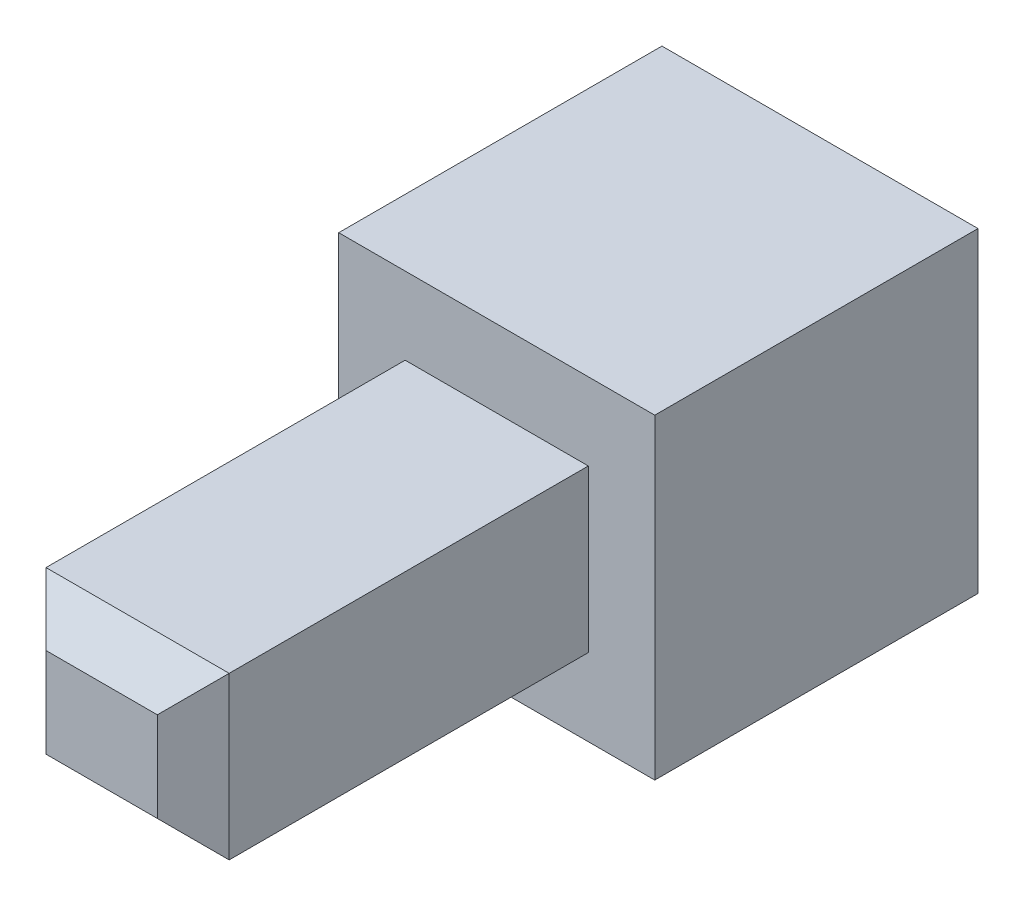
from build123d import *

# Parameters (mm, degrees)
BOSS_EXTRUDE1_DEPTH      = 2
BOSS_EXTRUDE1_DEPTH_BACK = 2
SKETCH2_W                = 8.799999809
SKETCH2_H                = 8.79999981
SKETCH2_W_2              = 6.399999809
SKETCH2_H_2              = 6.39999981
SKETCH3_W                = 8.799999809
SKETCH3_H                = 8.79999981
BOSS_EXTRUDE2_DEPTH      = 5
SKETCH4_W                = 5.099999879
SKETCH4_H                = 4.499999898
BOSS_EXTRUDE3_DEPTH      = 11
CHAMFER1_SIZE            = 1


with BuildPart() as part:
    # Sketch2 → Boss-Extrude1 (new, two sides: drawn at the far end of the back side and taken through both)
    with BuildSketch(Plane.XY.offset(-12.400000378).offset(-BOSS_EXTRUDE1_DEPTH_BACK)):
        with Locations((-28.752555167, 91.282627708)):
            Rectangle(SKETCH2_W, SKETCH2_H)
        with Locations((-28.752555167, 91.282627708)):
            Rectangle(SKETCH2_W_2, SKETCH2_H_2, mode=Mode.SUBTRACT)
    extrude(amount=BOSS_EXTRUDE1_DEPTH + BOSS_EXTRUDE1_DEPTH_BACK)

    # Sketch3 → Boss-Extrude2 (add)
    with BuildSketch(Plane.XY.offset(-10.400000378)):
        with Locations((-28.752555167, 91.282627708)):
            Rectangle(SKETCH3_W, SKETCH3_H)
    extrude(amount=BOSS_EXTRUDE2_DEPTH)

    # Sketch4 → Boss-Extrude3 (add)
    with BuildSketch(Plane.XY.offset(-5.400000378)):
        with Locations((-28.752555167, 91.282627708)):
            Rectangle(SKETCH4_W, SKETCH4_H)
    extrude(amount=BOSS_EXTRUDE3_DEPTH)

    # Chamfer1
    chamfer1_edges = [part.edges().sort_by_distance(p)[0] for p in [
        (-28.752555166, 93.532627657, 5.599999622),
        (-26.202555227, 91.282627708, 5.599999622),
        (-28.752555166, 89.032627759, 5.599999622),
        (-31.302555106, 91.282627708, 5.599999622),
    ]]
    chamfer(chamfer1_edges, length=CHAMFER1_SIZE)


solid = part.part
